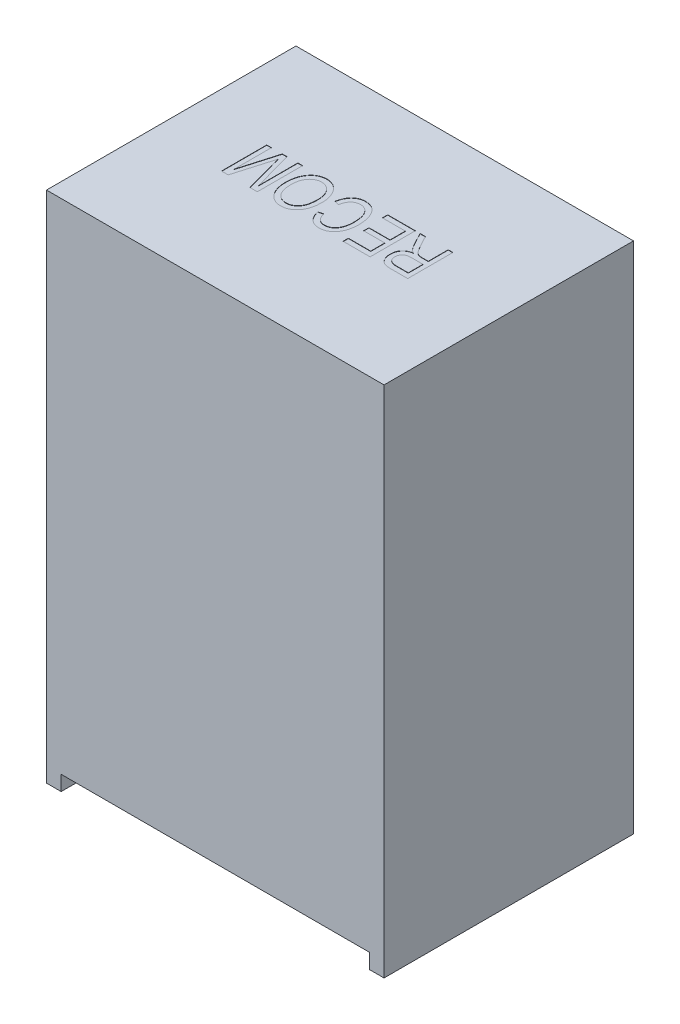
from build123d import *

# Parameters (mm, degrees)
SKETCH1_W           = 11.5
SKETCH1_H           = 8.5
BOSS_EXTRUDE1_DEPTH = 17.5
SKETCH2_W           = 10.5
SKETCH2_H           = 8.5
CUT_EXTRUDE1_DEPTH  = 0.51
SKETCH4_R           = 0.5
CUT_EXTRUDE3_DEPTH  = 0.01
CUT_EXTRUDE4_DEPTH  = 0.01


with BuildPart() as part:
    # Sketch1 → Boss-Extrude1 (new body)
    with BuildSketch(Plane(origin=(0, 0, 0), x_dir=(1, 0, 0), z_dir=(0, 1, 0))):
        Rectangle(SKETCH1_W, SKETCH1_H)
    extrude(amount=BOSS_EXTRUDE1_DEPTH)

    # Sketch2 → Cut-Extrude1 (cut)
    with BuildSketch(Plane.XZ):
        Rectangle(SKETCH2_W, SKETCH2_H)
    extrude(amount=-CUT_EXTRUDE1_DEPTH, mode=Mode.SUBTRACT)

    # Sketch4 → Cut-Extrude3 (cut)
    with BuildSketch(Plane(origin=(0, 0, -4.25), x_dir=(-1, 0, 0), z_dir=(0, 0, -1))):
        with Locations((-2.54, 1.51)):
            Circle(SKETCH4_R)
    extrude(amount=-CUT_EXTRUDE3_DEPTH, mode=Mode.SUBTRACT)

    # Sketch5 → Cut-Extrude4 (cut)
    with BuildSketch(Plane(origin=(0, 17.5, 0), x_dir=(1, 0, 0), z_dir=(0, 1, 0))):
        with BuildLine():
            Line((3.015665043, 0.831971813), (3.015665043, -0.709019398))
            Line((3.015665043, -0.709019398), (2.449675983, -0.709019398))
            add(Edge.make_bspline(
                [(2.449675983, -0.709019398), (2.435392304, -0.708938934), (2.407744774, -0.708783189), (2.367698356, -0.706470218), (2.330546212, -0.703171412), (2.296232197, -0.698405389), (2.26480894, -0.692799543), (2.236370246, -0.685055798), (2.210690005, -0.676621238), (2.180463777, -0.662682172), (2.146244138, -0.640660908), (2.109031977, -0.607769452), (2.076561831, -0.56690307), (2.04764238, -0.519998463), (2.023899962, -0.46732151), (2.007080319, -0.409878056), (1.996927089, -0.34841811), (1.995659171, -0.306091522), (1.995008527, -0.284371252)],
                knots=[0, 0, 0, 0, 0.957635919, 1.853602921, 2.688875264, 3.457888691, 4.176190018, 4.827208561, 5.432822301, 5.986390625, 7.054747822, 8.148857704, 9.301562339, 10.541054864, 11.836189034, 13.163051712, 14.544194391, 16, 16, 16, 16], degree=3))
            add(Edge.make_bspline(
                [(1.995008527, -0.284371252), (1.99534988, -0.269978125), (1.996016649, -0.24186385), (2.000025651, -0.200651595), (2.007096969, -0.161482937), (2.017603213, -0.12455558), (2.030221795, -0.089525395), (2.046417759, -0.056868663), (2.065129186, -0.026112182), (2.086825878, 0.002487294), (2.111265988, 0.02873199), (2.138205098, 0.052770985), (2.168256178, 0.073609233), (2.200487093, 0.092495154), (2.235456356, 0.108790552), (2.272992548, 0.122546317), (2.313227773, 0.133426245), (2.341026107, 0.138786724), (2.355240239, 0.141527699)],
                knots=[0, 0, 0, 0, 1.121876415, 2.19137531, 3.223949102, 4.219388443, 5.180726412, 6.121767895, 7.055309798, 7.98310721, 8.914383918, 9.846793912, 10.791230962, 11.759648879, 12.755485972, 13.793860249, 14.871933835, 16, 16, 16, 16], degree=3))
            add(Edge.make_bspline(
                [(2.355240239, 0.141527699), (2.344695959, 0.147275411), (2.32464932, 0.158202882), (2.297848638, 0.176837457), (2.273929577, 0.194064829), (2.260763409, 0.207234413), (2.254550472, 0.213448961)],
                knots=[0, 0, 0, 0, 1.159130627, 2.203723279, 3.152361336, 4, 4, 4, 4], degree=3))
            add(Edge.make_bspline(
                [(2.254550472, 0.213448961), (2.242063085, 0.228521738), (2.216947892, 0.258836785), (2.182518959, 0.307200641), (2.149540576, 0.357512579), (2.130174117, 0.392904434), (2.120401684, 0.41076338)],
                knots=[0, 0, 0, 0, 0.982253192, 1.975551771, 2.978451105, 4, 4, 4, 4], degree=3))
            Line((2.120401684, 0.41076338), (1.894944163, 0.831971813))
            Line((1.894944163, 0.831971813), (2.076936225, 0.831971813))
            Line((2.076936225, 0.831971813), (2.254863173, 0.502384813))
            add(Edge.make_bspline(
                [(2.254863173, 0.502384813), (2.263150559, 0.486930099), (2.279002349, 0.457368921), (2.302547981, 0.415409188), (2.324366182, 0.37752335), (2.34468748, 0.343913705), (2.362936716, 0.31423736), (2.380309744, 0.289357044), (2.395467103, 0.268101813), (2.413681432, 0.246224176), (2.435802395, 0.224332494), (2.461190368, 0.201691807), (2.486746849, 0.184294909), (2.512720615, 0.171011054), (2.541324159, 0.162267917), (2.573551277, 0.155721107), (2.610847682, 0.152160767), (2.637289772, 0.151751852), (2.651368217, 0.151534136)],
                knots=[0, 0, 0, 0, 1.483494143, 2.837570132, 4.070207475, 5.181709378, 6.16033008, 7.016386932, 7.748320287, 8.368145667, 9.421904523, 10.378344883, 11.241682452, 12.030373519, 12.836277254, 13.763198992, 14.809069961, 16, 16, 16, 16], degree=3))
            Line((2.651368217, 0.151534136), (2.85556206, 0.151534136))
            Line((2.85556206, 0.151534136), (2.85556206, 0.831971813))
            Line((2.85556206, 0.831971813), (3.015665043, 0.831971813))
        make_face()
        with BuildLine():
            Line((2.85556206, -0.02858172), (2.480007993, -0.02858172))
            add(Edge.make_bspline(
                [(2.480007993, -0.02858172), (2.460715568, -0.028959812), (2.42455968, -0.029668393), (2.37396514, -0.034318865), (2.330724485, -0.042887244), (2.294054912, -0.054980722), (2.262970611, -0.071556533), (2.23589228, -0.091799827), (2.211651119, -0.115780176), (2.191652214, -0.143964358), (2.175037738, -0.175068855), (2.163757077, -0.209141513), (2.156089647, -0.245463995), (2.155442865, -0.270570685), (2.15511151, -0.283433148)],
                knots=[0, 0, 0, 0, 1.472846091, 2.760257298, 3.872921329, 4.831650159, 5.69663992, 6.549651953, 7.404887885, 8.288274496, 9.178088419, 10.086493483, 11.019687313, 12, 12, 12, 12], degree=3))
            add(Edge.make_bspline(
                [(2.15511151, -0.283433148), (2.155396401, -0.292717191), (2.155951804, -0.310816677), (2.158985793, -0.337339806), (2.164582672, -0.362277445), (2.172524437, -0.38571847), (2.18240962, -0.407614875), (2.19481941, -0.427975411), (2.209566738, -0.446607665), (2.226158009, -0.463972748), (2.245036526, -0.479510548), (2.266476209, -0.492450504), (2.289865613, -0.503907811), (2.315452175, -0.513162602), (2.34318728, -0.520410641), (2.373035337, -0.525215987), (2.404990455, -0.528503792), (2.427048229, -0.528767568), (2.438418742, -0.528903542)],
                knots=[0, 0, 0, 0, 1.044945206, 2.037148109, 2.998935724, 3.915084151, 4.817845283, 5.696903301, 6.590859038, 7.486736354, 8.395345577, 9.33279486, 10.298009282, 11.322143252, 12.388977231, 13.518936305, 14.721042082, 16, 16, 16, 16], degree=3))
            Line((2.438418742, -0.528903542), (2.85556206, -0.528903542))
            Line((2.85556206, -0.528903542), (2.85556206, -0.02858172))
        make_face(mode=Mode.SUBTRACT)
        Polygon((1.73484118, 0.831971813), (1.73484118, -0.709019398), (0.814249028, -0.709019398), (0.814249028, -0.528903542), (1.574738197, -0.528903542), (1.574738197, -0.048594593), (0.854274773, -0.048594593), (0.854274773, 0.131521263), (1.574738197, 0.131521263), (1.574738197, 0.651855957), (0.794236155, 0.651855957), (0.794236155, 0.831971813), align=None)
        with BuildLine():
            Line((-0.346497599, 0.291624246), (-0.506600582, 0.331649991))
            add(Edge.make_bspline(
                [(-0.506600582, 0.331649991), (-0.501829463, 0.352866989), (-0.492527771, 0.394231282), (-0.475067279, 0.453719783), (-0.454714588, 0.508955066), (-0.431831121, 0.559985978), (-0.407017443, 0.607192731), (-0.379045593, 0.650006085), (-0.348302119, 0.688472364), (-0.315420668, 0.723226337), (-0.279990398, 0.753406529), (-0.242905644, 0.780059914), (-0.203654951, 0.80228039), (-0.16257805, 0.820439753), (-0.119760161, 0.834671073), (-0.075007007, 0.844518473), (-0.028468212, 0.851109401), (0.003287642, 0.851690519), (0.019362733, 0.851984686)],
                knots=[0, 0, 0, 0, 1.28922044, 2.513442024, 3.673007215, 4.776830106, 5.827500731, 6.832022649, 7.803999827, 8.743849815, 9.66425458, 10.559455276, 11.447931646, 12.33337188, 13.21872583, 14.118353182, 15.047493909, 16, 16, 16, 16], degree=3))
            add(Edge.make_bspline(
                [(0.019362733, 0.851984686), (0.033550305, 0.851788551), (0.061361273, 0.851404081), (0.102291221, 0.847071134), (0.141737313, 0.840715608), (0.179552664, 0.831267926), (0.215866264, 0.81935373), (0.250478905, 0.804691907), (0.283627289, 0.787326787), (0.315268296, 0.767319397), (0.345475749, 0.744278239), (0.374404204, 0.718289593), (0.401557752, 0.688748421), (0.427234876, 0.656034517), (0.451603312, 0.620267003), (0.474881623, 0.581421395), (0.496271481, 0.539066912), (0.516517406, 0.493931239), (0.535171414, 0.446176601), (0.55049723, 0.395777952), (0.563951139, 0.343507345), (0.575419483, 0.289206445), (0.583664948, 0.23268559), (0.589500001, 0.174038958), (0.593440074, 0.113333765), (0.593882488, 0.072114371), (0.594107426, 0.05115707)],
                knots=[0, 0, 0, 0, 0.921121005, 1.8056133, 2.67040233, 3.514377161, 4.334332635, 5.150394009, 5.952862848, 6.762354685, 7.578837179, 8.417691682, 9.284809544, 10.181422086, 11.116567612, 12.094173645, 13.120585634, 14.196358798, 15.306518391, 16.447844343, 17.615314784, 18.811617913, 20.050550251, 21.323062097, 22.638956355, 24, 24, 24, 24], degree=3))
            add(Edge.make_bspline(
                [(0.594107426, 0.05115707), (0.593887895, 0.030511684), (0.593457326, -0.009980355), (0.58947259, -0.069427981), (0.583835844, -0.126563835), (0.57489527, -0.181197244), (0.564123006, -0.23354668), (0.550671803, -0.283363689), (0.534704597, -0.330782473), (0.516289606, -0.375631796), (0.495916235, -0.418019793), (0.473717295, -0.457839155), (0.449738547, -0.494880191), (0.424162031, -0.529448968), (0.396853641, -0.561195333), (0.367516976, -0.590202641), (0.336496583, -0.616436963), (0.304008513, -0.640349491), (0.269968973, -0.661078191), (0.235073937, -0.679485389), (0.1990625, -0.694758664), (0.162065663, -0.707309287), (0.1241193, -0.717065265), (0.085209082, -0.723772969), (0.045433007, -0.728504079), (0.01854301, -0.728855166), (0.004978481, -0.729032271)],
                knots=[0, 0, 0, 0, 1.355095116, 2.65776402, 3.909870136, 5.122541271, 6.290068247, 7.417112276, 8.507673222, 9.572493115, 10.597729848, 11.593310423, 12.563163512, 13.492386605, 14.414173163, 15.309288628, 16.197683675, 17.079068066, 17.954536164, 18.811491617, 19.666833809, 20.519379772, 21.374064851, 22.235787637, 23.110051606, 24, 24, 24, 24], degree=3))
            add(Edge.make_bspline(
                [(0.004978481, -0.729032271), (-0.009837043, -0.728651921), (-0.038939761, -0.727904785), (-0.081906841, -0.722583281), (-0.123114208, -0.713148917), (-0.16283591, -0.700170043), (-0.201101037, -0.684069553), (-0.237616791, -0.663712078), (-0.272725865, -0.640042704), (-0.305820792, -0.612290051), (-0.337258696, -0.581532829), (-0.365653801, -0.546594599), (-0.392472341, -0.508942227), (-0.415950425, -0.467305366), (-0.437945877, -0.42283585), (-0.456155457, -0.374423701), (-0.47360649, -0.323108648), (-0.482187976, -0.287164686), (-0.486587709, -0.268736195)],
                knots=[0, 0, 0, 0, 0.969148585, 1.903736758, 2.826785899, 3.730310196, 4.634631807, 5.538027439, 6.460975827, 7.40040228, 8.359931585, 9.333412464, 10.34173472, 11.380359485, 12.456904674, 13.583902902, 14.761265506, 16, 16, 16, 16], degree=3))
            Line((-0.486587709, -0.268736195), (-0.326484726, -0.228710449))
            add(Edge.make_bspline(
                [(-0.326484726, -0.228710449), (-0.322866072, -0.241676012), (-0.315808611, -0.266962756), (-0.303249658, -0.303282227), (-0.289513619, -0.337121907), (-0.274585188, -0.368573155), (-0.25796117, -0.397363055), (-0.24012744, -0.423726218), (-0.221053475, -0.447736038), (-0.200338638, -0.468886244), (-0.17867235, -0.487969639), (-0.155390686, -0.504317539), (-0.130686953, -0.517974696), (-0.104784382, -0.5294552), (-0.07760112, -0.538090586), (-0.049047782, -0.544451183), (-0.019200262, -0.548202988), (0.001215617, -0.548676724), (0.011545205, -0.548916415)],
                knots=[0, 0, 0, 0, 1.274827499, 2.486296693, 3.637698816, 4.732866786, 5.781146847, 6.783409552, 7.745577291, 8.681189198, 9.583979081, 10.476943643, 11.369744444, 12.253932728, 13.156290603, 14.066553906, 15.021756508, 16, 16, 16, 16], degree=3))
            add(Edge.make_bspline(
                [(0.011545205, -0.548916415), (0.031932378, -0.54815716), (0.071714855, -0.546675588), (0.129179767, -0.534489115), (0.182562239, -0.514734605), (0.223229544, -0.491277802), (0.253461573, -0.468721932), (0.274864043, -0.44931185), (0.295328541, -0.427964647), (0.31455571, -0.404388925), (0.332129049, -0.37831423), (0.349293881, -0.350432105), (0.36467106, -0.320096059), (0.379289066, -0.287762097), (0.391973022, -0.25302243), (0.403210254, -0.216061661), (0.412937919, -0.176945943), (0.420723932, -0.135598025), (0.426524238, -0.092054844), (0.430992966, -0.046275773), (0.433393216, 0.001724489), (0.4337982, 0.03447732), (0.434004443, 0.05115707)],
                knots=[0, 0, 0, 0, 1.477319852, 2.882765608, 4.239071619, 5.5901645, 6.270494264, 6.971711204, 7.682800365, 8.413585745, 9.174705695, 9.961627353, 10.786552627, 11.639271465, 12.533754274, 13.466330389, 14.439856922, 15.455412122, 16.515914326, 17.624622774, 18.79031228, 20, 20, 20, 20], degree=3))
            add(Edge.make_bspline(
                [(0.434004443, 0.05115707), (0.433604751, 0.076180077), (0.432829519, 0.124714046), (0.427995257, 0.19521645), (0.419243314, 0.260891043), (0.407347582, 0.321815266), (0.391198831, 0.377648616), (0.372463831, 0.428957877), (0.349469007, 0.475220746), (0.323251171, 0.516624312), (0.29398542, 0.553122899), (0.262412555, 0.584923666), (0.228329645, 0.611700747), (0.19215157, 0.633965169), (0.153339414, 0.65080566), (0.112438197, 0.66312419), (0.069134186, 0.670431662), (0.039507773, 0.671382741), (0.024365952, 0.67186883)],
                knots=[0, 0, 0, 0, 1.437065497, 2.787294602, 4.055458609, 5.239956664, 6.348318907, 7.390106744, 8.372560959, 9.309120415, 10.199089469, 11.054089278, 11.876775321, 12.682652122, 13.486748469, 14.299179022, 15.1307241, 16, 16, 16, 16], degree=3))
            add(Edge.make_bspline(
                [(0.024365952, 0.67186883), (0.013093332, 0.671558945), (-0.009120596, 0.670948283), (-0.041868564, 0.66638255), (-0.073550222, 0.659333555), (-0.104058634, 0.648948269), (-0.13321147, 0.635381525), (-0.161170792, 0.619055789), (-0.187951237, 0.599771684), (-0.213502619, 0.577706829), (-0.2374438, 0.552513376), (-0.259340582, 0.524176475), (-0.279398685, 0.492977717), (-0.29687304, 0.458496851), (-0.312498213, 0.421172372), (-0.326246107, 0.380761566), (-0.337830586, 0.337294477), (-0.343562137, 0.307092459), (-0.346497599, 0.291624246)],
                knots=[0, 0, 0, 0, 0.928238582, 1.829195527, 2.718541612, 3.598220604, 4.477899596, 5.362883569, 6.261136532, 7.192387853, 8.139765768, 9.118675424, 10.13801499, 11.190128329, 12.298336808, 13.468533125, 14.703488264, 16, 16, 16, 16], degree=3))
        make_face()
        with BuildLine():
            add(Edge.make_bspline(
                [(-0.686716437, 0.081801782), (-0.687260435, 0.050202201), (-0.688319799, -0.01133384), (-0.696403731, -0.100800008), (-0.710114081, -0.184614935), (-0.729038075, -0.2629273), (-0.753673965, -0.335590615), (-0.783692025, -0.402755298), (-0.819487169, -0.464060132), (-0.860417189, -0.519414824), (-0.905590449, -0.568443323), (-0.953367143, -0.611677531), (-1.004361214, -0.647845441), (-1.05790645, -0.677377015), (-1.113960941, -0.701033788), (-1.173116571, -0.716895911), (-1.23470934, -0.727492117), (-1.276738069, -0.728514108), (-1.298047163, -0.729032271)],
                knots=[0, 0, 0, 0, 1.330963612, 2.591877185, 3.780001124, 4.905609826, 5.981685458, 7.007499675, 7.999259564, 8.966107442, 9.901487757, 10.803214703, 11.675503145, 12.528426463, 13.374815265, 14.231257297, 15.103225221, 16, 16, 16, 16], degree=3))
            add(Edge.make_bspline(
                [(-1.298047163, -0.729032271), (-1.312027246, -0.728722714), (-1.33963903, -0.728111315), (-1.380586619, -0.723507188), (-1.420584248, -0.716548169), (-1.459596968, -0.705960753), (-1.497838202, -0.692954562), (-1.53502329, -0.676639955), (-1.571177626, -0.657330832), (-1.606448531, -0.635641171), (-1.640294954, -0.610822958), (-1.67245401, -0.583301642), (-1.702968292, -0.553187473), (-1.731365171, -0.520252565), (-1.758011577, -0.484841002), (-1.782761885, -0.44675409), (-1.805965452, -0.406093698), (-1.82704436, -0.362704909), (-1.84639372, -0.317025841), (-1.862270077, -0.268778253), (-1.876672164, -0.21870673), (-1.887569698, -0.166382849), (-1.89694825, -0.112093773), (-1.902916206, -0.055581153), (-1.906828516, 0.003049485), (-1.907274698, 0.042811662), (-1.907501682, 0.063039713)],
                knots=[0, 0, 0, 0, 0.899728372, 1.777035685, 2.649634903, 3.510599637, 4.376335739, 5.247695836, 6.12114593, 7.013034258, 7.910859183, 8.819846926, 9.735545707, 10.667834891, 11.616590462, 12.586185849, 13.589866893, 14.628140742, 15.68982564, 16.780439222, 17.895646611, 19.041909795, 20.218887519, 21.440738676, 22.698037367, 24, 24, 24, 24], degree=3))
            add(Edge.make_bspline(
                [(-1.907501682, 0.063039713), (-1.907002197, 0.09067538), (-1.906024096, 0.144792025), (-1.898938106, 0.22403886), (-1.886324527, 0.29934331), (-1.869229124, 0.370759084), (-1.847453321, 0.438331778), (-1.820339458, 0.501779349), (-1.788744903, 0.561639137), (-1.76320741, 0.598310197), (-1.750525711, 0.616520729)],
                knots=[0, 0, 0, 0, 1.133573908, 2.21978419, 3.260104344, 4.262924452, 5.229693681, 6.168399862, 7.090443156, 8, 8, 8, 8], degree=3))
            add(Edge.make_bspline(
                [(-1.750525711, 0.616520729), (-1.735900133, 0.635196078), (-1.707312702, 0.671699269), (-1.658674229, 0.719937923), (-1.606657632, 0.760823141), (-1.551234754, 0.794315677), (-1.492454649, 0.820169689), (-1.430409169, 0.838699557), (-1.364845318, 0.849854493), (-1.319979939, 0.851265435), (-1.29710906, 0.851984686)],
                knots=[0, 0, 0, 0, 1.070156674, 2.091748428, 3.083988789, 4.050862299, 5.007465552, 5.975231952, 6.967840518, 8, 8, 8, 8], degree=3))
            add(Edge.make_bspline(
                [(-1.29710906, 0.851984686), (-1.274131495, 0.851289118), (-1.229036664, 0.849924026), (-1.163025207, 0.838397902), (-1.100584844, 0.819250046), (-1.041378628, 0.792842934), (-0.986008399, 0.758349181), (-0.934173662, 0.716337697), (-0.885544684, 0.667015307), (-0.857242887, 0.629481462), (-0.842754306, 0.610266706)],
                knots=[0, 0, 0, 0, 1.027712946, 2.016947528, 2.987811303, 3.944031492, 4.90967079, 5.89821231, 6.924028725, 8, 8, 8, 8], degree=3))
            add(Edge.make_bspline(
                [(-0.842754306, 0.610266706), (-0.830221688, 0.591712364), (-0.805230634, 0.554713507), (-0.773689847, 0.495330203), (-0.74673431, 0.433460738), (-0.724805261, 0.368576683), (-0.707568032, 0.300954998), (-0.695468512, 0.23037765), (-0.688176494, 0.157004262), (-0.687208523, 0.107147406), (-0.686716437, 0.081801782)],
                knots=[0, 0, 0, 0, 0.958921302, 1.912166611, 2.876389157, 3.848196333, 4.843783955, 5.863771395, 6.914010006, 8, 8, 8, 8], degree=3))
        make_face()
        with BuildLine():
            add(Edge.make_bspline(
                [(-0.84681942, 0.084303391), (-0.847278397, 0.106933619), (-0.848172601, 0.1510231), (-0.853980147, 0.215227198), (-0.864274741, 0.275445844), (-0.878620356, 0.33174647), (-0.897060224, 0.384219135), (-0.919544621, 0.432885642), (-0.946162562, 0.477633213), (-0.976998562, 0.517850459), (-1.010213069, 0.554044124), (-1.04564754, 0.585626449), (-1.083194112, 0.61190864), (-1.122048228, 0.63416871), (-1.163026124, 0.651181199), (-1.205798393, 0.662946234), (-1.250255216, 0.670433233), (-1.280505894, 0.671385533), (-1.295858255, 0.67186883)],
                knots=[0, 0, 0, 0, 1.312373, 2.556838691, 3.734430473, 4.851580682, 5.92218495, 6.955255676, 7.955623695, 8.934876895, 9.88880355, 10.800906141, 11.68137439, 12.542096288, 13.392998608, 14.246559067, 15.11012045, 16, 16, 16, 16], degree=3))
            add(Edge.make_bspline(
                [(-1.295858255, 0.67186883), (-1.311518808, 0.671367515), (-1.342485405, 0.670376232), (-1.387959317, 0.6631222), (-1.431355127, 0.650826967), (-1.47292725, 0.633837029), (-1.512171991, 0.611435222), (-1.549828352, 0.584667381), (-1.585224543, 0.552757125), (-1.618697451, 0.516315143), (-1.648998418, 0.474908867), (-1.675817914, 0.429042812), (-1.697949951, 0.3782718), (-1.715872642, 0.323014335), (-1.730457565, 0.263375305), (-1.740016257, 0.198996508), (-1.746592443, 0.13019869), (-1.747124811, 0.082756769), (-1.7473987, 0.058349196)],
                knots=[0, 0, 0, 0, 0.878736935, 1.737581901, 2.576491555, 3.405387938, 4.251446712, 5.10693805, 5.993545411, 6.921050276, 7.879314889, 8.867607226, 9.896962605, 10.981016766, 12.12461493, 13.338373667, 14.630665936, 16, 16, 16, 16], degree=3))
            add(Edge.make_bspline(
                [(-1.7473987, 0.058349196), (-1.747249399, 0.042291704), (-1.746955348, 0.010666071), (-1.743695997, -0.036187825), (-1.738499814, -0.081704854), (-1.730896822, -0.125926006), (-1.721504173, -0.1688084), (-1.710402191, -0.210569476), (-1.696572791, -0.2509045), (-1.685822635, -0.277021691), (-1.680480656, -0.289999872)],
                knots=[0, 0, 0, 0, 1.078694861, 2.124516608, 3.15388928, 4.155540379, 5.137710323, 6.102651412, 7.057167582, 8, 8, 8, 8], degree=3))
            add(Edge.make_bspline(
                [(-1.680480656, -0.289999872), (-1.67148159, -0.308999071), (-1.653734458, -0.346467549), (-1.616979426, -0.396425206), (-1.575125847, -0.441442847), (-1.526481617, -0.479308102), (-1.47383771, -0.510373161), (-1.417652814, -0.532338943), (-1.35931233, -0.54655692), (-1.31939246, -0.54812639), (-1.299297968, -0.548916415)],
                knots=[0, 0, 0, 0, 1.03281879, 2.036830454, 3.038780936, 4.051047395, 5.060604537, 6.037387297, 7.012078312, 8, 8, 8, 8], degree=3))
            add(Edge.make_bspline(
                [(-1.299297968, -0.548916415), (-1.283217033, -0.548430311), (-1.251517248, -0.547472071), (-1.205188309, -0.540067724), (-1.160842811, -0.528407713), (-1.119150566, -0.510711379), (-1.079074097, -0.48936645), (-1.041738726, -0.46223785), (-1.006156174, -0.430984323), (-0.973319854, -0.394414692), (-0.943018838, -0.353132207), (-0.917110793, -0.306088982), (-0.895217742, -0.253861696), (-0.877593291, -0.19629603), (-0.863523152, -0.133583165), (-0.853758145, -0.065629854), (-0.847718102, 0.007581222), (-0.847126022, 0.058128196), (-0.84681942, 0.084303391)],
                knots=[0, 0, 0, 0, 0.879333998, 1.733400362, 2.560603334, 3.381294816, 4.205465494, 5.039363089, 5.899801755, 6.792002367, 7.722713802, 8.695281408, 9.72257703, 10.81554062, 11.984506408, 13.235281311, 14.568320825, 16, 16, 16, 16], degree=3))
        make_face(mode=Mode.SUBTRACT)
        with BuildLine():
            Line((-2.107630411, 0.831971813), (-2.107630411, -0.709019398))
            Line((-2.107630411, -0.709019398), (-2.358104023, -0.709019398))
            Line((-2.358104023, -0.709019398), (-2.657984415, 0.381994875))
            Line((-2.657984415, 0.381994875), (-2.718023034, 0.610266706))
            add(Edge.make_bspline(
                [(-2.718023034, 0.610266706), (-2.719980973, 0.60275581), (-2.724095141, 0.586973361), (-2.731087001, 0.562090921), (-2.738896978, 0.534942627), (-2.747016828, 0.505174824), (-2.756007244, 0.473151915), (-2.766146127, 0.438718655), (-2.77674488, 0.401810234), (-2.784006631, 0.376367295), (-2.787755388, 0.363232806)],
                knots=[0, 0, 0, 0, 0.725697868, 1.52489003, 2.416432129, 3.366907773, 4.409724083, 5.526171267, 6.722927622, 8, 8, 8, 8], degree=3))
            Line((-2.787755388, 0.363232806), (-3.101707331, -0.709019398))
            Line((-3.101707331, -0.709019398), (-3.328415656, -0.709019398))
            Line((-3.328415656, -0.709019398), (-3.328415656, 0.831971813))
            Line((-3.328415656, 0.831971813), (-3.168312673, 0.831971813))
            Line((-3.168312673, 0.831971813), (-3.168312673, -0.440096419))
            Line((-3.168312673, -0.440096419), (-2.798387226, 0.831971813))
            Line((-2.798387226, 0.831971813), (-2.63453183, 0.831971813))
            Line((-2.63453183, 0.831971813), (-2.267733394, -0.512955784))
            Line((-2.267733394, -0.512955784), (-2.267733394, 0.831971813))
            Line((-2.267733394, 0.831971813), (-2.107630411, 0.831971813))
        make_face()
    extrude(amount=-CUT_EXTRUDE4_DEPTH, mode=Mode.SUBTRACT)


solid = part.part
